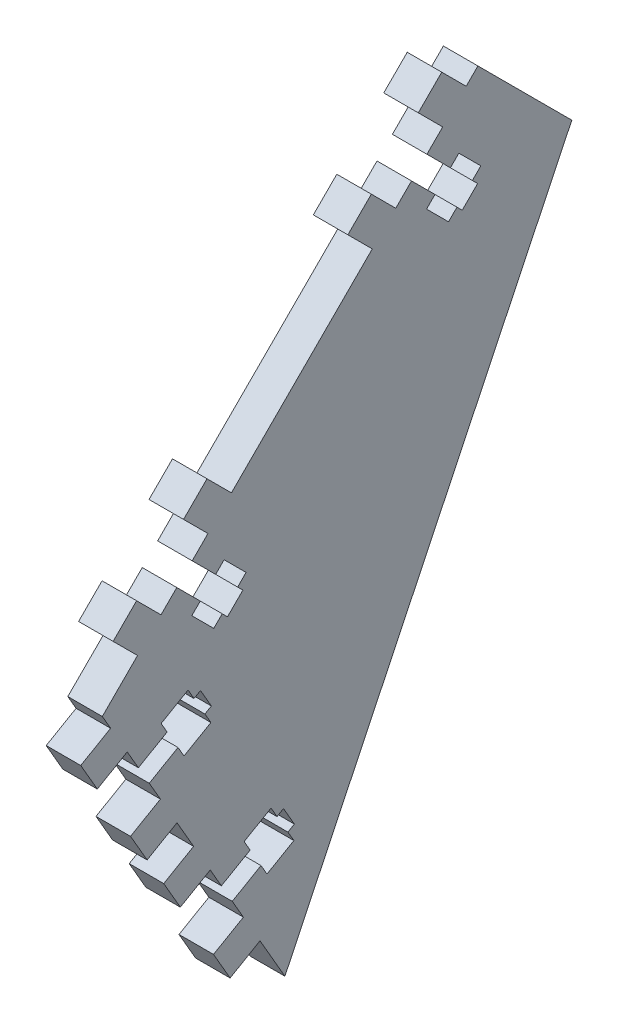
from build123d import *

# Parameters (mm, degrees)
BOSS_EXTRUDE1_DEPTH = 6.604
CUT_EXTRUDE1_DEPTH  = 7.604
BOSS_EXTRUDE2_DEPTH = 6.604


with BuildPart() as part:
    # Sketch1 → Boss-Extrude1 (new body)
    with BuildSketch(Plane(origin=(0, 0, 0), x_dir=(0, 0, -1), z_dir=(1, 0, 0))):
        Polygon((0, 0), (-34.925, 60.491874454), (36.917048969, 132.333923423), (54.877561211, 114.373411181), align=None)
    extrude(amount=-BOSS_EXTRUDE1_DEPTH)

    # Sketch2 → Cut-Extrude1 (cut, through all)
    with BuildSketch(Plane(origin=(0, 0, 0), x_dir=(0, 0, -1), z_dir=(1, 0, 0))):
        Polygon((31.654618882, 118.091237215), (27.164490821, 122.581365275), (24.218966813, 119.635841268), (28.709094874, 115.145713207), (27.092648772, 113.529267105), (31.295408637, 109.326507241), (32.911854739, 110.942953343), (33.917643424, 109.937164657), (36.863167432, 112.882688665), (35.857378746, 113.88847735), (37.473824848, 115.504923452), (33.271064983, 119.707683317), align=None)
        Polygon((-13.246661724, 73.18995661), (-17.736789784, 77.68008467), (-20.682313792, 74.734560662), (-16.192185731, 70.244432602), (-17.808631833, 68.6279865), (-13.605871969, 64.425226635), (-11.989425867, 66.041672737), (-10.983637181, 65.035884052), (-8.038113174, 67.981408059), (-9.043901859, 68.987196745), (-7.427455757, 70.603642847), (-11.630215622, 74.806402711), align=None)
        Polygon((-17.382330096, 54.69427888), (-18.525330096, 56.674012953), (-23.672638686, 53.702212953), (-22.529638686, 51.72247888), (-28.0289, 48.54747888), (-25.9461, 44.939963458), (-20.446838686, 48.114963458), (-19.303838686, 46.135229385), (-14.156530096, 49.107029385), (-15.299530096, 51.086763458), (-14.067695562, 51.797963458), (-16.150495562, 55.40547888), align=None)
        Polygon((-2.650330096, 29.177706383), (-7.797638686, 26.205906383), (-6.654638686, 24.22617231), (-12.1539, 21.05117231), (-10.0711, 17.443656888), (-4.571838686, 20.618656888), (-3.428838686, 18.638922815), (1.718469904, 21.610722815), (0.575469904, 23.590456888), (1.807304438, 24.301656888), (-0.275495562, 27.90917231), (-1.507330096, 27.19797231), align=None)
    extrude(amount=-CUT_EXTRUDE1_DEPTH, mode=Mode.SUBTRACT)

    # Sketch3 → Boss-Extrude2 (add)
    with BuildSketch(Plane(origin=(0, 0, 0), x_dir=(0, 0, -1), z_dir=(1, 0, 0))):
        Polygon((30.002251755, 134.758592576), (34.671984938, 130.088859393), (30.181856878, 125.598731332), (25.512123695, 130.268464515), align=None)
        Polygon((21.201600757, 116.618475211), (16.531867574, 121.288208394), (12.041739513, 116.798080333), (16.711472696, 112.12834715), align=None)
        Polygon((-14.719423728, 80.697450727), (-19.389156911, 85.36718391), (-14.89902885, 89.85731197), (-10.229295667, 85.187578787), align=None)
        Polygon((-28.369413032, 76.386927789), (-32.859541092, 71.896799728), (-28.189807909, 67.227066545), (-23.699679849, 71.717194606), align=None)
        Polygon((-39.056731767, 54.440243797), (-33.3375, 57.742243797), (-30.1625, 52.242982483), (-35.881731767, 48.940982483), align=None)
        Polygon((-23.8125, 41.244459855), (-29.531731767, 37.942459855), (-26.356731767, 32.443198541), (-20.6375, 35.745198541), align=None)
        Polygon((-23.181731767, 26.943937227), (-17.4625, 30.245937227), (-14.2875, 24.746675913), (-20.006731767, 21.444675913), align=None)
        Polygon((-13.656731767, 10.446153285), (-10.481731767, 4.946891971), (-4.7625, 8.248891971), (-7.9375, 13.748153285), align=None)
    extrude(amount=-BOSS_EXTRUDE2_DEPTH)


solid = part.part
